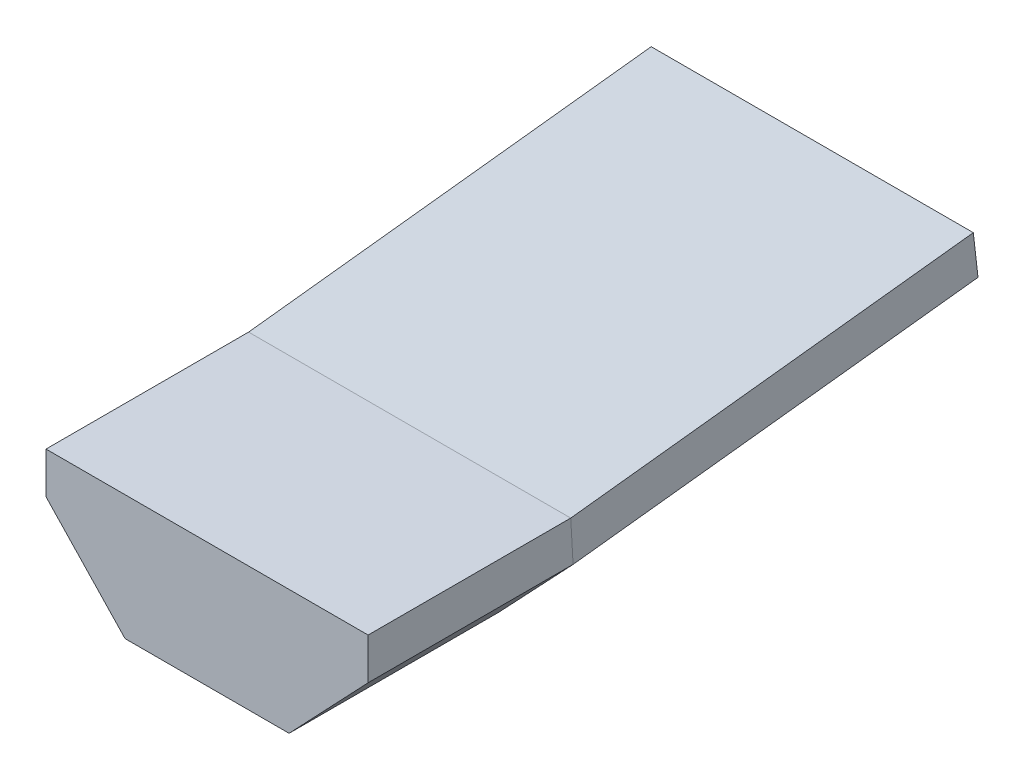
from build123d import *


with BuildPart() as part:
    # Sweep1: sweep along a path in Sketch2
    with BuildLine(Plane(origin=(0, 0, 0), x_dir=(0, 0, -1), z_dir=(1, 0, 0))) as sweep1_path:
        Line((0, 0), (10, 0))
        Line((10, 0), (29.871437114, 2.264064275))
    # Sketch1 → Sweep1 (sweep)
    with BuildSketch(Plane.XY):
        Polygon((7.95, 0), (7.95, -2.04), (4.048, -6.152414984), (-4.048, -6.152414984), (-7.95, -2.04), (-7.95, 0), align=None)
    sweep(path=sweep1_path.line, transition=Transition.RIGHT)


solid = part.part
